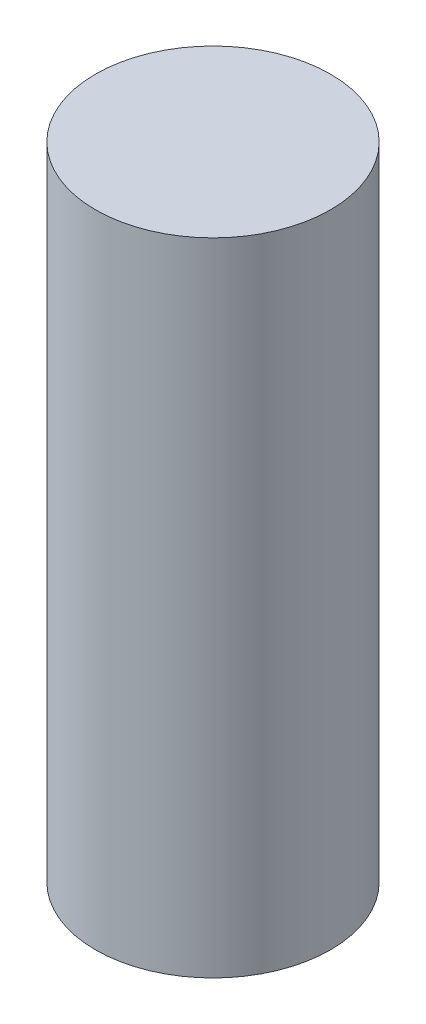
from build123d import *

# Parameters (mm, degrees)
SKETCH1_R           = 2.75
BOSS_EXTRUDE1_DEPTH = 15


with BuildPart() as part:
    # Sketch1 → Boss-Extrude1 (new body)
    with BuildSketch(Plane(origin=(0, 0, 0), x_dir=(1, 0, 0), z_dir=(0, 1, 0))):
        Circle(SKETCH1_R)
    extrude(amount=BOSS_EXTRUDE1_DEPTH)


solid = part.part
